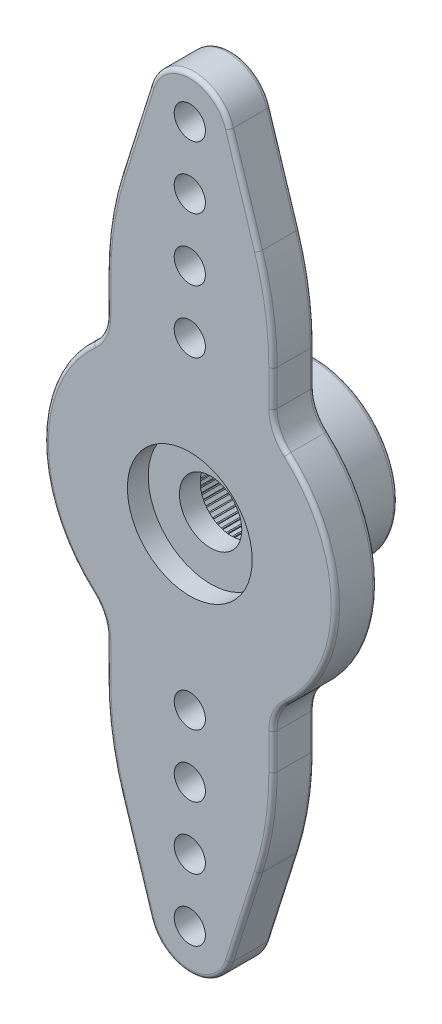
from build123d import *

# Parameters (mm, degrees)
SKETCH1_R                = 7
SKETCH1_R_2              = 1.5
SKETCH1_R_3              = 2
BOSS_EXTRUDE1_DEPTH      = 2
FILLET1_R                = 15
SKETCH2_R                = 0.75
CUT_EXTRUDE1_DEPTH       = 3
CIRPATTERN2_COUNT        = 2
FILLET1_OF_CIRPATTERN2_R = 15
FILLET2_R                = 2
SKETCH3_R                = 3
CUT_EXTRUDE2_DEPTH       = 1
SKETCH4_R                = 4
SKETCH4_R_2              = 3
BOSS_EXTRUDE2_DEPTH      = 4
SKETCH5_W                = 0.05
SKETCH5_H                = 0.5
BOSS_EXTRUDE3_DEPTH      = 4
CIRPATTERN3_COUNT        = 80
FILLET3_R                = 0.2


with BuildPart() as part:
    # Sketch1 → Boss-Extrude1 (new body)
    with BuildSketch(Plane.XY):
        Circle(SKETCH1_R)
        Circle(SKETCH1_R_2, mode=Mode.SUBTRACT)
        with BuildLine():
            Line((-1.906651599, 17.353887141), (-4, 10.744562647))
            Line((-4, 10.744562647), (-4, 5.744562647))
            ThreePointArc((-4, 5.744562647), (0, 7), (4, 5.744562647))
            Line((4, 5.744562647), (4, 10.744562647))
            Line((4, 10.744562647), (1.906651599, 17.353887141))
            ThreePointArc((1.906651599, 17.353887141), (1.976525132, 17.055529705), (2, 16.75))
            ThreePointArc((2, 16.75), (-0.305529705, 14.773474868), (-1.906651599, 17.353887141))
        make_face()
        with Locations((0, 16.75)):
            Circle(SKETCH1_R_3)
    boss_extrude1 = extrude(amount=BOSS_EXTRUDE1_DEPTH)

    # Fillet1
    fillet1_edges = [part.edges().sort_by_distance(p)[0] for p in [
        (-4, 10.744562647, 1),
        (4, 10.744562647, 1),
    ]]
    fillet(fillet1_edges, radius=FILLET1_R)

    # Sketch2 → Cut-Extrude1 (cut, through all)
    with BuildSketch(Plane.XY.offset(2)):
        with Locations((0, 16.75)):
            Circle(SKETCH2_R)
        with Locations((0, 13.75)):
            Circle(SKETCH2_R)
        with Locations((0, 10.75)):
            Circle(SKETCH2_R)
        with Locations((0, 7.75)):
            Circle(SKETCH2_R)
    cut_extrude1 = extrude(amount=-CUT_EXTRUDE1_DEPTH, mode=Mode.SUBTRACT)

    # CirPattern2: Boss-Extrude1, Cut-Extrude1 ×2 about axis
    cirpattern2_axis = Axis((0, 0, 0), (0, 0, 1))
    for i in range(1, CIRPATTERN2_COUNT):
        add(boss_extrude1.rotate(cirpattern2_axis, i * 360 / CIRPATTERN2_COUNT))
        add(cut_extrude1.rotate(cirpattern2_axis, i * 360 / CIRPATTERN2_COUNT), mode=Mode.SUBTRACT)

    # Fillet1 of CirPattern2
    fillet1_of_cirpattern2_edges = [part.edges().sort_by_distance(p)[0] for p in [
        (4, -10.744562647, 1),
        (-4, -10.744562647, 1),
    ]]
    fillet(fillet1_of_cirpattern2_edges, radius=FILLET1_OF_CIRPATTERN2_R)

    # Fillet2
    fillet2_edges = [part.edges().sort_by_distance(p)[0] for p in [
        (-4, 5.744562647, 1),
        (4, 5.744562647, 1),
        (4, -5.744562647, 1),
        (-4, -5.744562647, 1),
    ]]
    fillet(fillet2_edges, radius=FILLET2_R)

    # Sketch3 → Cut-Extrude2 (cut)
    with BuildSketch(Plane.XY.offset(2)):
        Circle(SKETCH3_R)
    extrude(amount=-CUT_EXTRUDE2_DEPTH, mode=Mode.SUBTRACT)

    # Sketch4 → Boss-Extrude2 (add)
    with BuildSketch(Plane(origin=(0, 0, 0), x_dir=(-1, 0, 0), z_dir=(0, 0, -1))):
        Circle(SKETCH4_R)
        Circle(SKETCH4_R_2, mode=Mode.SUBTRACT)
    extrude(amount=BOSS_EXTRUDE2_DEPTH)

    # Sketch5 → Boss-Extrude3 (add)
    with BuildSketch(Plane(origin=(0, 0, -4), x_dir=(-1, 0, 0), z_dir=(0, 0, -1))):
        with Locations((0, -3.144105088)):
            Rectangle(SKETCH5_W, SKETCH5_H)
    boss_extrude3 = extrude(amount=-BOSS_EXTRUDE3_DEPTH)

    # CirPattern3: Boss-Extrude3 ×80 about axis
    cirpattern3_axis = Axis((0, 0, 0), (0, 0, 1))
    for i in range(1, CIRPATTERN3_COUNT):
        add(boss_extrude3.rotate(cirpattern3_axis, i * 360 / CIRPATTERN3_COUNT))

    # Fillet3
    fillet3_edges = [part.edges().sort_by_distance(p)[0] for p in [
        (-7, 0, 0),
        (-7, 0, 2),
        (7, 0, 0),
        (7, 0, 2),
        (-4.174258142, 5.891707352, 0),
        (-4.174258142, 5.891707352, 2),
        (-4.174258142, -5.891707352, 0),
        (-4.174258142, -5.891707352, 2),
        (4.174258142, -5.891707352, 0),
        (4.174258142, -5.891707352, 2),
        (4.174258142, 5.891707352, 0),
        (4.174258142, 5.891707352, 2),
        (4, 0, 0),
        (2.603269296, 15.154457554, 2),
        (4, 0, -4),
        (0, 18.75, 2),
        (-4, 7.567039169, 0),
        (-4, 7.567039169, 2),
        (-2.603269296, 15.154457554, 2),
        (4, 7.567039169, 0),
        (3.823938493, 10.717347197, 0),
        (-3.823938493, 10.717347197, 0),
        (4, 7.567039169, 2),
        (3.823938493, 10.717347197, 2),
        (-3.823938493, 10.717347197, 2),
        (0, -18.75, 2),
        (2.603269296, -15.154457554, 2),
        (-2.603269296, -15.154457554, 0),
        (-2.603269296, -15.154457554, 2),
        (0, -18.75, 0),
        (2.603269296, -15.154457554, 0),
        (4, -7.567039169, 0),
        (-2.603269296, 15.154457554, 0),
        (4, -7.567039169, 2),
        (-4, -7.567039169, 0),
        (-3.823938493, -10.717347197, 0),
        (3.823938493, -10.717347197, 0),
        (0, 18.75, 0),
        (-4, -7.567039169, 2),
        (-3.823938493, -10.717347197, 2),
        (3.823938493, -10.717347197, 2),
        (2.603269296, 15.154457554, 0),
    ]]
    fillet(fillet3_edges, radius=FILLET3_R)


solid = part.part
